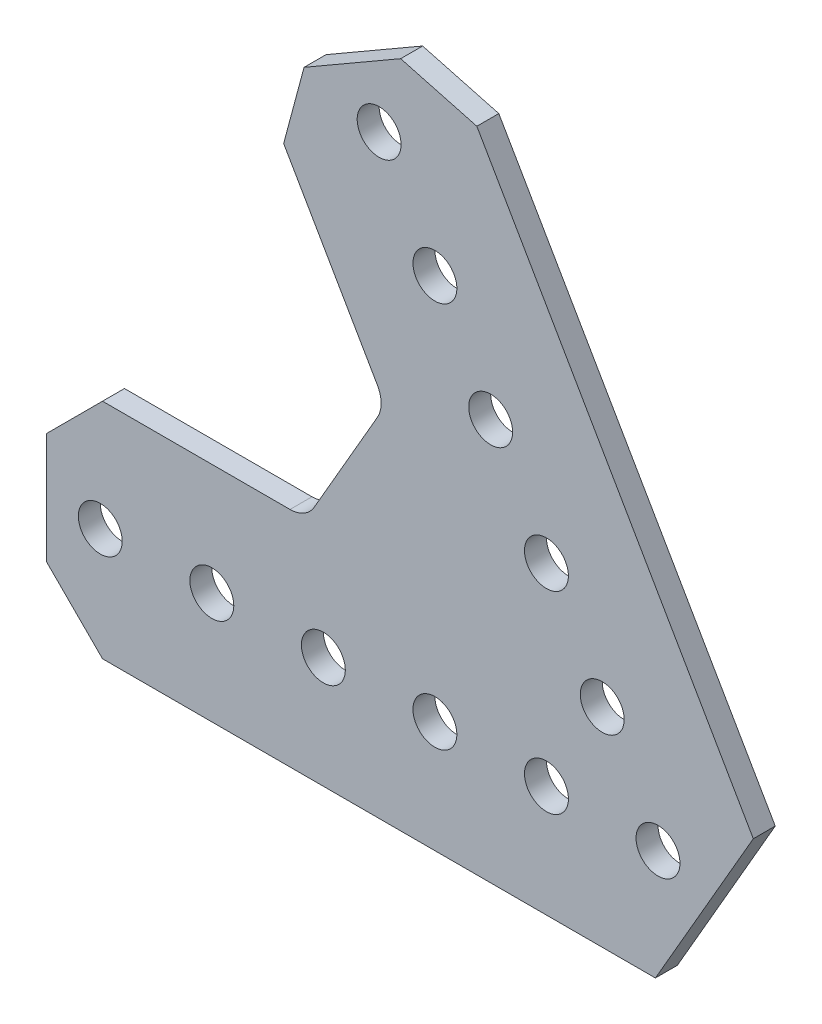
from build123d import *

# Parameters (mm, degrees)
SKETCH1_R           = 2.5
BOSS_EXTRUDE1_DEPTH = 2.5


with BuildPart() as part:
    # Sketch1 → Boss-Extrude1 (new body)
    with BuildSketch(Plane(origin=(0, 0, -1.25), x_dir=(-1, 0, 0), z_dir=(0, 0, -1))):
        with BuildLine():
            Line((0.293293937, -12.7), (63.246, -12.7))
            Line((63.246, -12.7), (69.596, -6.35))
            Line((69.596, -6.35), (69.596, 6.35))
            Line((69.596, 6.35), (63.246, 12.7))
            Line((63.246, 12.7), (41.897783942, 12.7))
            ThreePointArc((41.897783942, 12.7), (40.310283942, 13.125369343), (39.148153285, 14.2875))
            Line((39.148153285, 14.2875), (31.947414599, 26.759545256))
            ThreePointArc((31.947414599, 26.759545256), (31.522045256, 28.347045256), (31.947414599, 29.934545256))
            Line((31.947414599, 29.934545256), (42.621522628, 48.422642688))
            Line((42.621522628, 48.422642688), (40.297261314, 57.096904002))
            Line((40.297261314, 57.096904002), (29.298738686, 63.446904002))
            Line((29.298738686, 63.446904002), (20.624477372, 61.122642688))
            Line((20.624477372, 61.122642688), (-10.85187566, 6.604))
            Line((-10.85187566, 6.604), (0.293293937, -12.7))
        make_face()
        with Locations((12.7, 0)):
            Circle(SKETCH1_R, mode=Mode.SUBTRACT)
        with Locations((25.4, 0)):
            Circle(SKETCH1_R, mode=Mode.SUBTRACT)
        with Locations((38.1, 0)):
            Circle(SKETCH1_R, mode=Mode.SUBTRACT)
        Circle(SKETCH1_R, mode=Mode.SUBTRACT)
        with Locations((63.5, 0)):
            Circle(SKETCH1_R, mode=Mode.SUBTRACT)
        with Locations((50.8, 0)):
            Circle(SKETCH1_R, mode=Mode.SUBTRACT)
        with Locations((31.75, 54.99261314)):
            Circle(SKETCH1_R, mode=Mode.SUBTRACT)
        with Locations((25.4, 43.994090512)):
            Circle(SKETCH1_R, mode=Mode.SUBTRACT)
        with Locations((19.05, 32.995567884)):
            Circle(SKETCH1_R, mode=Mode.SUBTRACT)
        with Locations((12.7, 21.997045256)):
            Circle(SKETCH1_R, mode=Mode.SUBTRACT)
        with Locations((6.35, 10.998522628)):
            Circle(SKETCH1_R, mode=Mode.SUBTRACT)
    extrude(amount=-BOSS_EXTRUDE1_DEPTH)


solid = part.part
